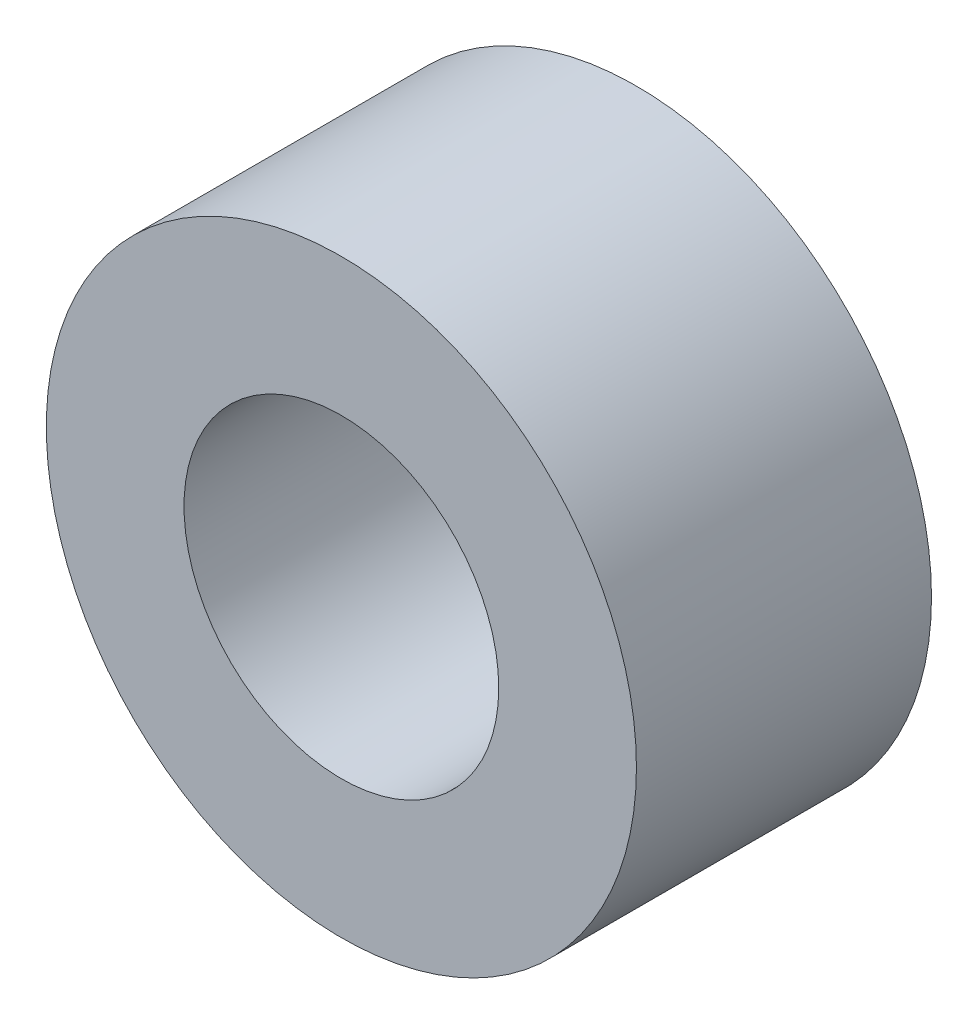
from build123d import *

# Parameters (mm, degrees)
SKETCH1_R           = 3
SKETCH1_R_2         = 1.6
EXTRUDE1_DEPTH      = 1.5
EXTRUDE1_DEPTH_BACK = 1.5


with BuildPart() as part:
    # Sketch1 → Extrude1 (new body, two sides)
    with BuildSketch(Plane.XY) as extrude1_sk:
        Circle(SKETCH1_R)
        Circle(SKETCH1_R_2, mode=Mode.SUBTRACT)
    extrude(amount=EXTRUDE1_DEPTH)
    extrude(extrude1_sk.sketch, amount=-EXTRUDE1_DEPTH_BACK)


solid = part.part
